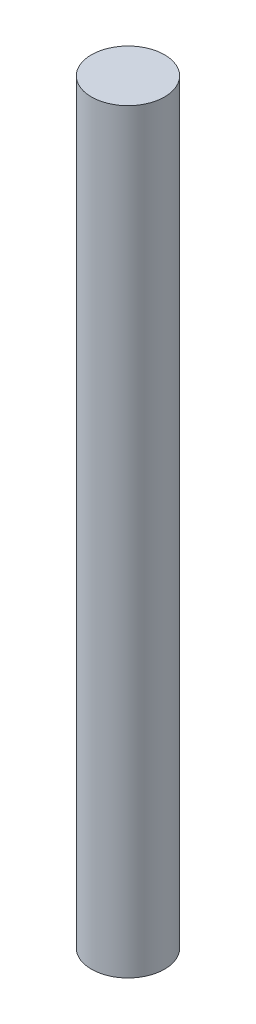
from build123d import *

# Parameters (mm, degrees)
SKETCH1_R           = 1.5
BOSS_EXTRUDE1_DEPTH = 31


with BuildPart() as part:
    # Sketch1 → Boss-Extrude1 (new body)
    with BuildSketch(Plane(origin=(0, 0, 0), x_dir=(1, 0, 0), z_dir=(0, 1, 0))):
        Circle(SKETCH1_R)
    extrude(amount=BOSS_EXTRUDE1_DEPTH)


solid = part.part
